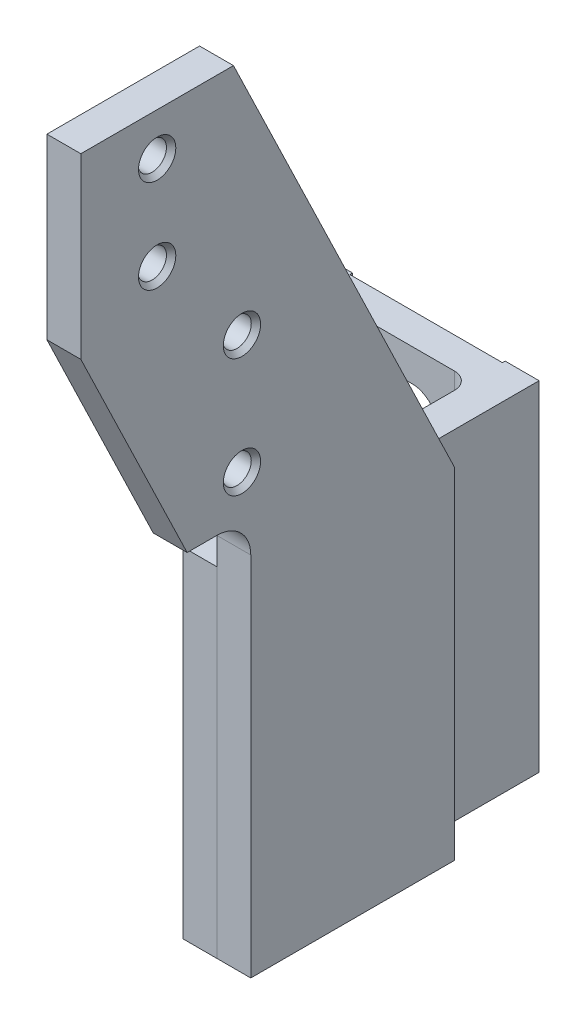
from build123d import *

# Parameters (mm, degrees)
SKETCH1_W                        = 82.55
SKETCH1_H                        = 127
EXTRUDE1_DEPTH                   = 12.7
SKETCH2_W                        = 57.15
SKETCH2_H                        = 127
CUT_EXTRUDE1_DEPTH               = 1.016
CUT_EXTRUDE2_REACH               = 14.7
SKETCH4_W                        = 12.7
SKETCH4_H                        = 127
EXTRUDE3_DEPTH                   = 107.95
EXTRUDE4_DEPTH                   = 12.7
CUT_EXTRUDE3_REACH               = 97.25
CUT_EXTRUDE4_DEPTH               = 96.25
F_1_2_13_TAPPED_HOLE1_AT_2_COUNT = 2
F_1_2_13_TAPPED_HOLE1_AT_2_PITCH = 34.925
F_1_2_13_TAPPED_HOLE2_AT_2_COUNT = 2
F_1_2_13_TAPPED_HOLE2_AT_2_PITCH = 44.45
FILLET1_R                        = 6.35
F_1_2_13_TAPPED_HOLE3_AT_2_COUNT = 2
F_1_2_13_TAPPED_HOLE3_AT_2_PITCH = 34.925
F_1_2_13_TAPPED_HOLE4_AT_2_COUNT = 2
F_1_2_13_TAPPED_HOLE4_AT_2_PITCH = 44.45


with BuildPart() as part:
    # Sketch1 → Extrude1 (new body)
    with BuildSketch(Plane.XY):
        with Locations((-41.275, 63.5)):
            Rectangle(SKETCH1_W, SKETCH1_H)
    extrude(amount=EXTRUDE1_DEPTH)

    # Sketch2 → Cut-Extrude1 (cut)
    with BuildSketch(Plane(origin=(0, 0, 0), x_dir=(-1, 0, 0), z_dir=(0, 0, -1))):
        with Locations((41.275, 63.5)):
            Rectangle(SKETCH2_W, SKETCH2_H)
    extrude(amount=-CUT_EXTRUDE1_DEPTH, mode=Mode.SUBTRACT)

    # Sketch3 → Cut-Extrude2 (cut, up to next)
    with BuildSketch(Plane.XY.offset(12.7), mode=Mode.PRIVATE) as cut_extrude2_sk1:
        with BuildLine():
            Line((-47.625, 114.935), (-34.925, 114.935))
            ThreePointArc((-34.925, 114.935), (-25.4, 105.41), (-34.925, 95.885))
            Line((-34.925, 95.885), (-47.625, 95.885))
            ThreePointArc((-47.625, 95.885), (-57.15, 105.41), (-47.625, 114.935))
        make_face()
    cut_extrude2_tool1 = extrude(cut_extrude2_sk1.sketch, amount=-CUT_EXTRUDE2_REACH, mode=Mode.PRIVATE) & part.part
    add(cut_extrude2_tool1.solids().sort_by_distance((-41.275, 105.41, 12.7))[0], mode=Mode.SUBTRACT)
    # Sketch3 → Cut-Extrude2 (cut, up to next)
    with BuildSketch(Plane.XY.offset(12.7), mode=Mode.PRIVATE) as cut_extrude2_sk2:
        with BuildLine():
            Line((-47.625, 31.115), (-34.925, 31.115))
            ThreePointArc((-34.925, 31.115), (-25.4, 21.59), (-34.925, 12.065))
            Line((-34.925, 12.065), (-47.625, 12.065))
            ThreePointArc((-47.625, 12.065), (-57.15, 21.59), (-47.625, 31.115))
        make_face()
    cut_extrude2_tool2 = extrude(cut_extrude2_sk2.sketch, amount=-CUT_EXTRUDE2_REACH, mode=Mode.PRIVATE) & part.part
    add(cut_extrude2_tool2.solids().sort_by_distance((-41.275, 21.59, 12.7))[0], mode=Mode.SUBTRACT)
    # Sketch3 → Cut-Extrude2 (cut, up to next)
    with BuildSketch(Plane.XY.offset(12.7), mode=Mode.PRIVATE) as cut_extrude2_sk3:
        with BuildLine():
            Line((-47.625, 76.835), (-34.925, 76.835))
            ThreePointArc((-34.925, 76.835), (-25.4, 67.31), (-34.925, 57.785))
            Line((-34.925, 57.785), (-47.625, 57.785))
            ThreePointArc((-47.625, 57.785), (-57.15, 67.31), (-47.625, 76.835))
        make_face()
    cut_extrude2_tool3 = extrude(cut_extrude2_sk3.sketch, amount=-CUT_EXTRUDE2_REACH, mode=Mode.PRIVATE) & part.part
    add(cut_extrude2_tool3.solids().sort_by_distance((-41.275, 67.31, 12.7))[0], mode=Mode.SUBTRACT)

    # Sketch4 → Extrude3 (add)
    with BuildSketch(Plane.XY.offset(12.7)):
        with Locations((-6.35, 63.5)):
            Rectangle(SKETCH4_W, SKETCH4_H)
    extrude(amount=EXTRUDE3_DEPTH)

    # Sketch5 → Extrude4 (add)
    with BuildSketch(Plane(origin=(0, 0, 0), x_dir=(0, 0, -1), z_dir=(1, 0, 0))):
        with BuildLine():
            Line((-120.65, 0), (-44.45, 0))
            Line((-44.45, 0), (-44.45, 299.085))
            Line((-44.45, 299.085), (-184.277, 299.085))
            Line((-184.277, 299.085), (-184.277, 149.86))
            Line((-184.277, 149.86), (-133.35, 149.86))
            ThreePointArc((-133.35, 149.86), (-124.369743879, 146.140256121), (-120.65, 137.16))
            Line((-120.65, 137.16), (-120.65, 0))
        make_face()
    extrude(amount=EXTRUDE4_DEPTH)

    # Sketch6 → Cut-Extrude3 (cut, up to next)
    with BuildSketch(Plane(origin=(12.7, 0, 0), x_dir=(0, 0, -1), z_dir=(1, 0, 0)), mode=Mode.PRIVATE) as cut_extrude3_sk1:
        Polygon((-127.127, 299.085), (-44.45, 127.635), (-44.45, 299.085), align=None)
    cut_extrude3_tool1 = extrude(cut_extrude3_sk1.sketch, amount=-CUT_EXTRUDE3_REACH, mode=Mode.PRIVATE) & part.part
    add(cut_extrude3_tool1.solids().sort_by_distance((12.7, 241.935, 72.009))[0], mode=Mode.SUBTRACT)

    # Sketch7 → Cut-Extrude4 (cut, through all)
    with BuildSketch(Plane(origin=(12.7, 0, 0), x_dir=(0, 0, -1), z_dir=(1, 0, 0))):
        Polygon((-184.277, 149.86), (-144.469555556, 149.86), (-184.277, 232.41), align=None)
    extrude(amount=-CUT_EXTRUDE4_DEPTH, mode=Mode.SUBTRACT)

    # Sketch8 → 1/2-13 Tapped Hole1 (revolve, cut)
    with BuildSketch(Plane(origin=(12.7, 248.285, 155.702), x_dir=(0, 0, -1), z_dir=(0, 1, 0))):
        Polygon((0, 0), (0, 12.7), (6.985, 12.7), (5.35813, 10.828500149), (5.35813, 1.871499851), (6.985, 0), align=None)
    f_1_2_13_tapped_hole1 = revolve(axis=Axis((19.05, 248.285, 155.702), (-1, 0, 0)), mode=Mode.SUBTRACT)

    # 1/2-13 Tapped Hole1 at 2: 1/2-13 Tapped Hole1 ×2
    with Locations(*[(0, i * F_1_2_13_TAPPED_HOLE1_AT_2_PITCH, 0) for i in range(1, F_1_2_13_TAPPED_HOLE1_AT_2_COUNT)]):
        add(f_1_2_13_tapped_hole1, mode=Mode.SUBTRACT)

    # Sketch10 → 1/2-13 Tapped Hole2 (revolve, cut)
    with BuildSketch(Plane(origin=(12.7, 210.185, 123.952), x_dir=(0, 0, -1), z_dir=(0, 1, 0))):
        Polygon((0, 0), (0, 12.7), (6.985, 12.7), (5.35813, 10.828500149), (5.35813, 1.871499851), (6.985, 0), align=None)
    f_1_2_13_tapped_hole2 = revolve(axis=Axis((19.05, 210.185, 123.952), (-1, 0, 0)), mode=Mode.SUBTRACT)

    # 1/2-13 Tapped Hole2 at 2: 1/2-13 Tapped Hole2 ×2
    with Locations(*[(0, -i * F_1_2_13_TAPPED_HOLE2_AT_2_PITCH, 0) for i in range(1, F_1_2_13_TAPPED_HOLE2_AT_2_COUNT)]):
        add(f_1_2_13_tapped_hole2, mode=Mode.SUBTRACT)

    # Fillet1
    fillet1_edges = [part.edges().sort_by_distance(p)[0] for p in [
        (-12.7, 63.5, 12.7),
    ]]
    fillet(fillet1_edges, radius=FILLET1_R)

    # Sketch16 → 1/2-13 Tapped Hole3 (revolve, cut)
    with BuildSketch(Plane(origin=(-95.25, 283.21, 155.702), x_dir=(0, 0, 1), z_dir=(0, 1, 0))):
        Polygon((0, 0), (0, 12.7), (6.985, 12.7), (5.35813, 10.828500149), (5.35813, 1.871499851), (6.985, 0), align=None)
    f_1_2_13_tapped_hole3 = revolve(axis=Axis((-101.6, 283.21, 155.702), (1, 0, 0)), mode=Mode.SUBTRACT)

    # 1/2-13 Tapped Hole3 at 2: 1/2-13 Tapped Hole3 ×2
    with Locations(*[(0, -i * F_1_2_13_TAPPED_HOLE3_AT_2_PITCH, 0) for i in range(1, F_1_2_13_TAPPED_HOLE3_AT_2_COUNT)]):
        add(f_1_2_13_tapped_hole3, mode=Mode.SUBTRACT)

    # Sketch18 → 1/2-13 Tapped Hole4 (revolve, cut)
    with BuildSketch(Plane(origin=(-95.25, 210.185, 123.952), x_dir=(0, 0, 1), z_dir=(0, 1, 0))):
        Polygon((0, 0), (0, 12.7), (6.985, 12.7), (5.35813, 10.828500149), (5.35813, 1.871499851), (6.985, 0), align=None)
    f_1_2_13_tapped_hole4 = revolve(axis=Axis((-101.6, 210.185, 123.952), (1, 0, 0)), mode=Mode.SUBTRACT)

    # 1/2-13 Tapped Hole4 at 2: 1/2-13 Tapped Hole4 ×2
    with Locations(*[(0, -i * F_1_2_13_TAPPED_HOLE4_AT_2_PITCH, 0) for i in range(1, F_1_2_13_TAPPED_HOLE4_AT_2_COUNT)]):
        add(f_1_2_13_tapped_hole4, mode=Mode.SUBTRACT)


solid = part.part
